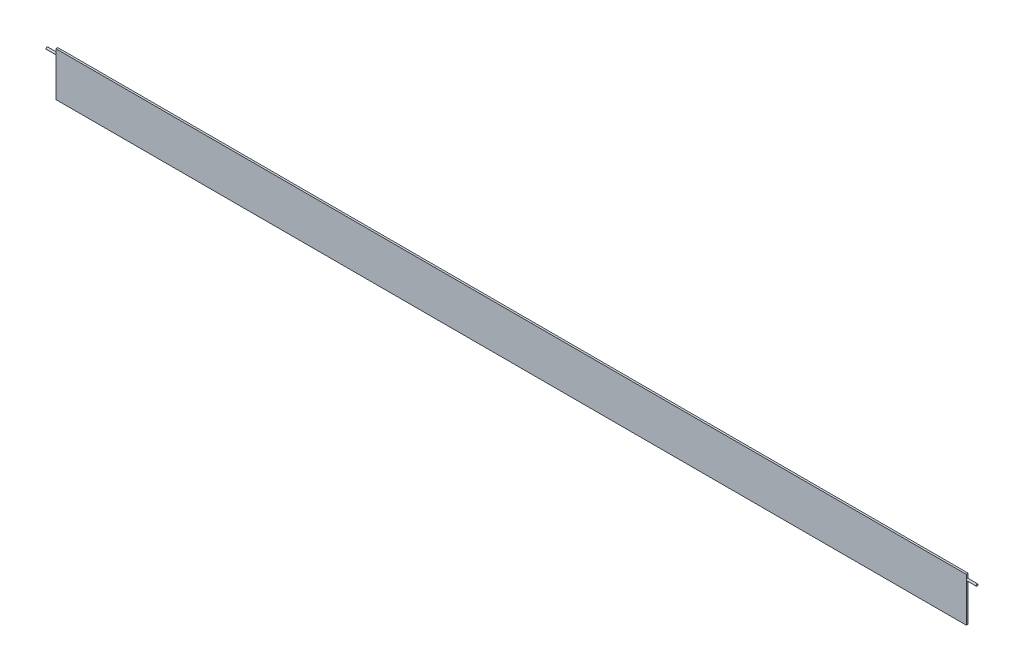
from build123d import *

# Parameters (mm, degrees)
SKETCH1_W                = 1181.1
SKETCH1_H                = 57.15
BOSS_EXTRUDE1_DEPTH      = 1.27
SKETCH2_R                = 1.27
BOSS_EXTRUDE2_DEPTH      = 12.7
BOSS_EXTRUDE2_DEPTH_BACK = 1193.8


with BuildPart() as part:
    # Sketch1 → Boss-Extrude1 (new body, symmetric)
    with BuildSketch(Plane.XY):
        Rectangle(SKETCH1_W, SKETCH1_H)
    extrude(amount=BOSS_EXTRUDE1_DEPTH, both=True)

    # Sketch2 → Boss-Extrude2 (add, two sides)
    with BuildSketch(Plane.ZY.offset(590.55)) as boss_extrude2_sk:
        with Locations((0, 22.225)):
            Circle(SKETCH2_R)
    extrude(amount=BOSS_EXTRUDE2_DEPTH)
    extrude(boss_extrude2_sk.sketch, amount=-BOSS_EXTRUDE2_DEPTH_BACK)


solid = part.part
